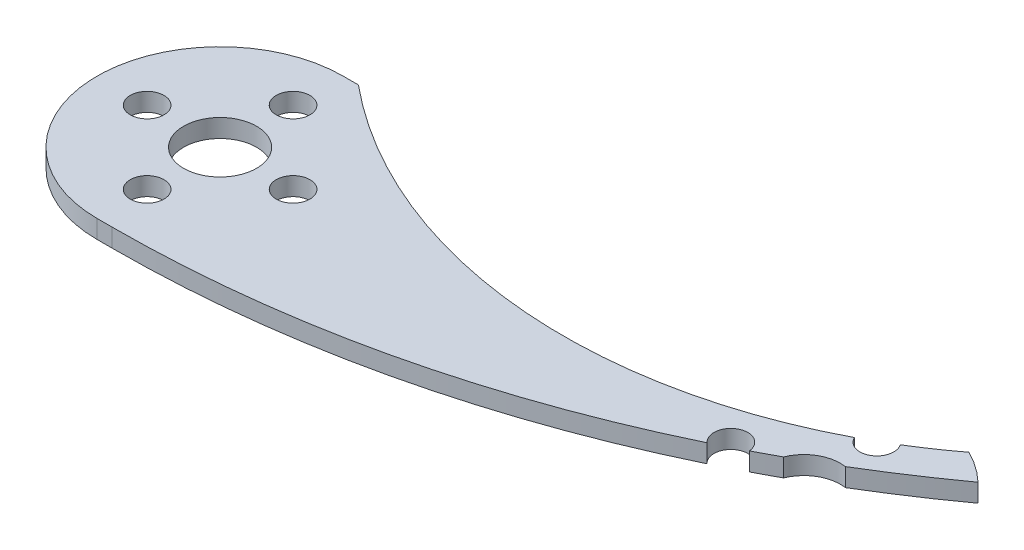
from build123d import *

# Parameters (mm, degrees)
SKETCH1_R           = 1.85
SKETCH1_R_2         = 4
BOSS_EXTRUDE1_DEPTH = 2
CUT_EXTRUDE1_DEPTH  = 3


with BuildPart() as part:
    # Sketch1 → Boss-Extrude1 (new body)
    with BuildSketch(Plane(origin=(0, 0, 0), x_dir=(1, 0, 0), z_dir=(0, 1, 0))):
        with BuildLine():
            Line((39.272536472, 22.976935119), (-24.727463528, 22.976935119))
            ThreePointArc((-24.727463528, 22.976935119), (-38.227463528, 9.476935119), (-24.727463528, -4.023064881))
            Line((-24.727463528, -4.023064881), (39.272536472, -4.023064881))
            ThreePointArc((39.272536472, -4.023064881), (52.772536472, 9.476935119), (39.272536472, 22.976935119))
        make_face()
        with Locations((-24.727463528, 17.476935119)):
            Circle(SKETCH1_R, mode=Mode.SUBTRACT)
        with Locations((-24.727463528, 9.476935119)):
            Circle(SKETCH1_R_2, mode=Mode.SUBTRACT)
        with Locations((-32.727463528, 9.476935119)):
            Circle(SKETCH1_R, mode=Mode.SUBTRACT)
        with Locations((-24.727463528, 1.476935119)):
            Circle(SKETCH1_R, mode=Mode.SUBTRACT)
        with Locations((-16.727463528, 9.476935119)):
            Circle(SKETCH1_R, mode=Mode.SUBTRACT)
        with Locations((39.272536472, 17.476935119)):
            Circle(SKETCH1_R, mode=Mode.SUBTRACT)
        with Locations((39.272536472, 9.476935119)):
            Circle(SKETCH1_R_2, mode=Mode.SUBTRACT)
        with Locations((31.272536472, 9.476935119)):
            Circle(SKETCH1_R, mode=Mode.SUBTRACT)
        with Locations((47.272536472, 9.476935119)):
            Circle(SKETCH1_R, mode=Mode.SUBTRACT)
        with Locations((39.272536472, 1.476935119)):
            Circle(SKETCH1_R, mode=Mode.SUBTRACT)
    extrude(amount=BOSS_EXTRUDE1_DEPTH)

    # Sketch2 → Cut-Extrude1 (cut, through all)
    with BuildSketch(Plane(origin=(0, 2, 0), x_dir=(1, 0, 0), z_dir=(0, 1, 0))):
        with BuildLine():
            Line((-23.067485442, 22.976935119), (42.777422328, 34.888708749))
            Line((42.777422328, 34.888708749), (45.278061915, 21.567578781))
            ThreePointArc((45.278061915, 21.567578781), (10.860216356, 10.387702722), (-23.067485442, 22.976935119))
        make_face()
        with BuildLine():
            Line((48.61621824, 19.220938968), (77.215135597, 13.399575669))
            Line((77.215135597, 13.399575669), (46.358944508, -30.129693903))
            Line((46.358944508, -30.129693903), (-23.067485442, -4.023064881))
            ThreePointArc((-23.067485442, -4.023064881), (14.611544165, 1.933144375), (48.61621824, 19.220938968))
        make_face()
    extrude(amount=-CUT_EXTRUDE1_DEPTH, mode=Mode.SUBTRACT)


solid = part.part
